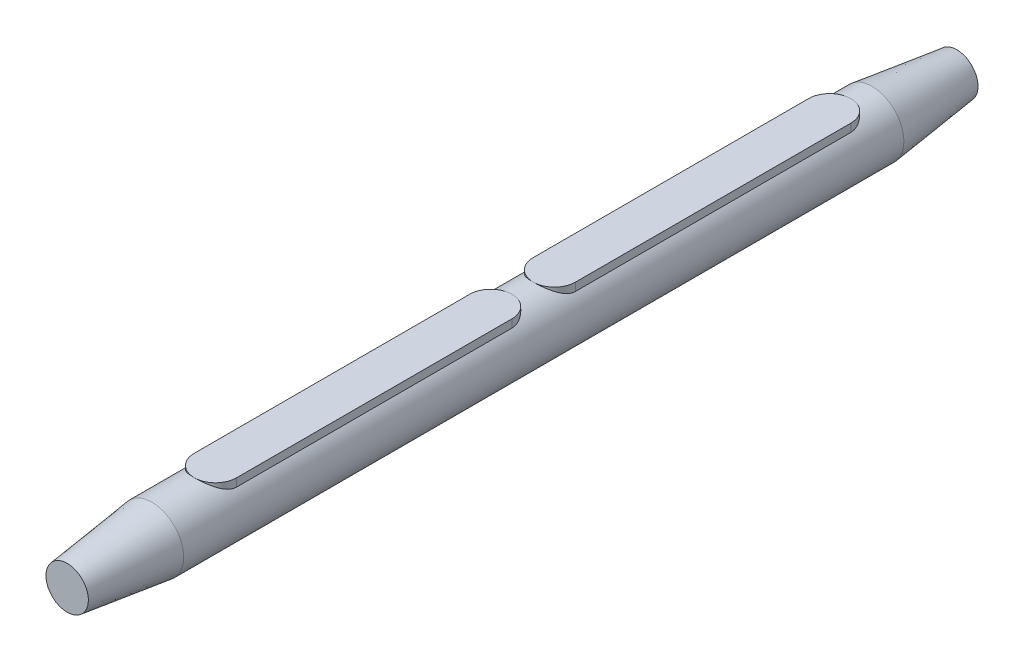
from build123d import *

# Parameters (mm, degrees)
SECTION_2_R         = 150
BOSS_EXTRUDE1_DEPTH = 3400
BOSS_EXTRUDE2_REACH = 3816.774


with BuildPart() as part:
    # Section 2 → Boss-Extrude1 (new body)
    with BuildSketch(Plane.XY):
        Circle(SECTION_2_R)
    extrude(amount=BOSS_EXTRUDE1_DEPTH)

    # ConoPopa → Revolve1 (revolve)
    with BuildSketch(Plane(origin=(0, 0, 0), x_dir=(0, 0, -1), z_dir=(1, 0, 0))):
        Polygon((400, 0), (400, 100), (0, 150), (0, 0), align=None)
    revolve(axis=Axis((0, 0, 0), (0, 0, -1)))

    # ConoProa → Revolve2 (revolve)
    with BuildSketch(Plane(origin=(0, 0, 0), x_dir=(0, 0, -1), z_dir=(1, 0, 0))):
        Polygon((-3800, 0), (-3800, 100), (-3400, 150), (-3400, 0), align=None)
    revolve(axis=Axis((0, 0, 3400), (0, 0, 1)))

    # Boss-Extrude2: up to this face of the body
    boss_extrude2_end = part.part.faces().sort_by_distance((-150, 0, 1700))[0]
    # Sketch1 → Boss-Extrude2 (add, up to the picked face)
    with BuildSketch(Plane(origin=(0, 150, 0), x_dir=(1, 0, 0), z_dir=(0, 1, 0)), mode=Mode.PRIVATE) as boss_extrude2_sk1:
        with BuildLine():
            Line((-100, -1500), (-100, -200))
            ThreePointArc((-100, -200), (0, -100), (100, -200))
            Line((100, -200), (100, -1500))
            ThreePointArc((100, -1500), (0, -1600), (-100, -1500))
        make_face()
    boss_extrude2_tool1 = split(extrude(boss_extrude2_sk1.sketch, amount=-BOSS_EXTRUDE2_REACH, mode=Mode.PRIVATE), bisect_by=boss_extrude2_end, keep=Keep.BOTH, mode=Mode.PRIVATE)
    # Sketch1 → Boss-Extrude2 (add, up to the picked face)
    with BuildSketch(Plane(origin=(0, 150, 0), x_dir=(1, 0, 0), z_dir=(0, 1, 0)), mode=Mode.PRIVATE) as boss_extrude2_sk2:
        with BuildLine():
            Line((-100, -1800), (-100, -3100))
            ThreePointArc((-100, -3100), (0, -3200), (100, -3100))
            Line((100, -3100), (100, -1800))
            ThreePointArc((100, -1800), (0, -1700), (-100, -1800))
        make_face()
    boss_extrude2_tool2 = split(extrude(boss_extrude2_sk2.sketch, amount=-BOSS_EXTRUDE2_REACH, mode=Mode.PRIVATE), bisect_by=boss_extrude2_end, keep=Keep.BOTH, mode=Mode.PRIVATE)
    add(boss_extrude2_tool1.solids().sort_by(Axis((0, 150, 850), (0, -1, 0)))[0])
    add(boss_extrude2_tool1.solids().sort_by(Axis((0, 150, 850), (0, -1, 0)))[1])
    add(boss_extrude2_tool2.solids().sort_by(Axis((0, 150, 2450), (0, -1, 0)))[0])
    add(boss_extrude2_tool2.solids().sort_by(Axis((0, 150, 2450), (0, -1, 0)))[1])


solid = part.part
